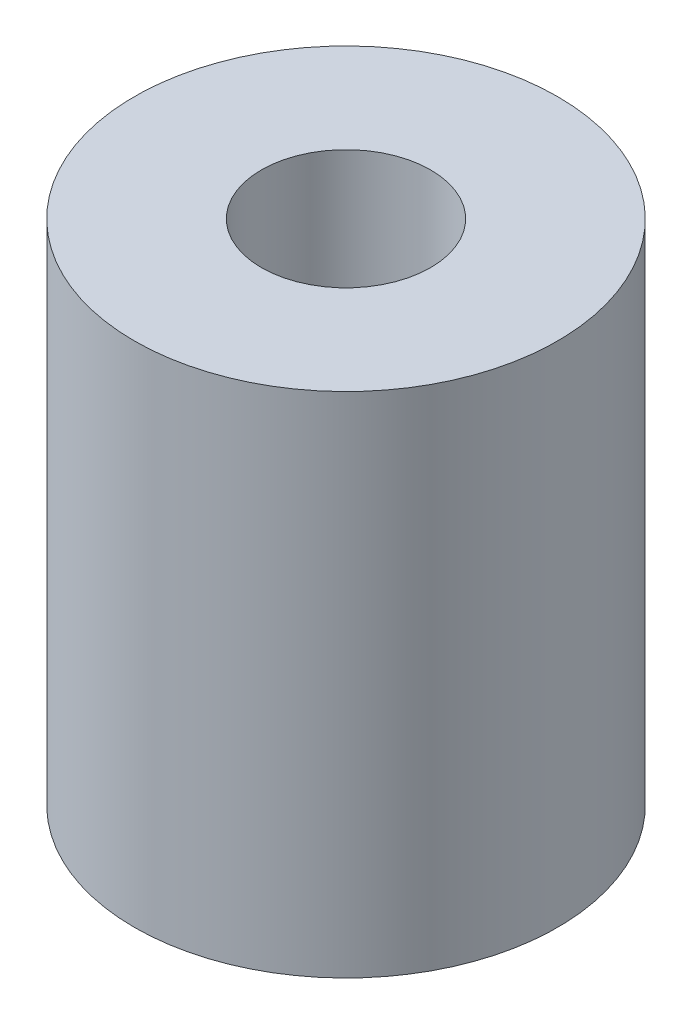
from build123d import *

# Parameters (mm, degrees)
SKETCH1_R           = 2.5
SKETCH1_R_2         = 1
BOSS_EXTRUDE1_DEPTH = 6


with BuildPart() as part:
    # Sketch1 → Boss-Extrude1 (new body)
    with BuildSketch(Plane(origin=(0, 0, 0), x_dir=(1, 0, 0), z_dir=(0, 1, 0))):
        Circle(SKETCH1_R)
        Circle(SKETCH1_R_2, mode=Mode.SUBTRACT)
    extrude(amount=BOSS_EXTRUDE1_DEPTH)


solid = part.part
